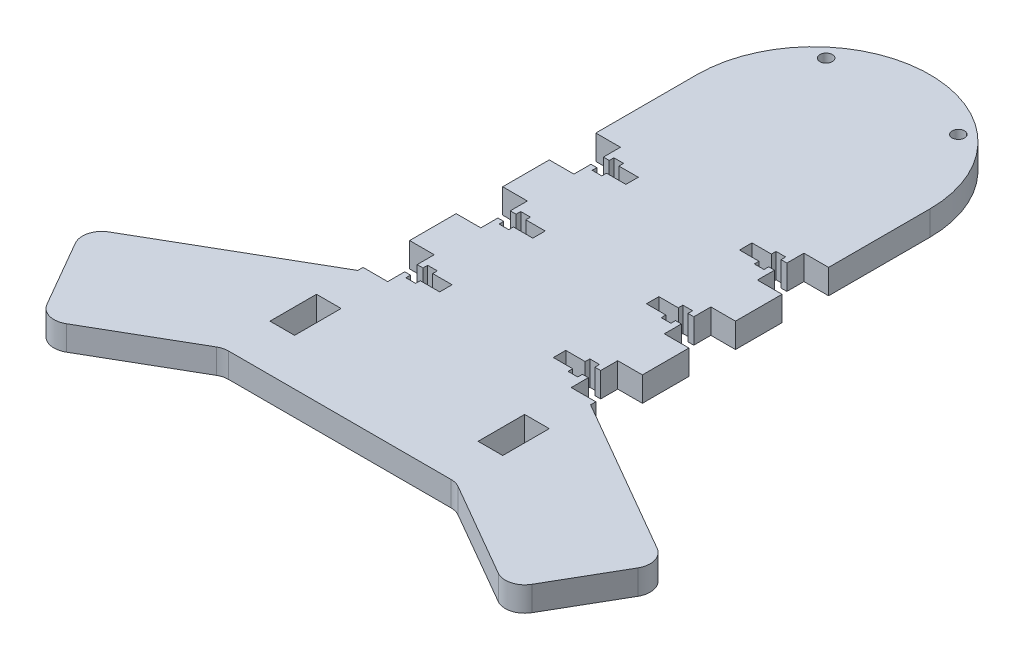
from build123d import *

# Parameters (mm, degrees)
BOSS_EXTRUDE1_DEPTH = 6.35
CUT_EXTRUDE1_REACH  = 8.35
SKETCH3_W           = 6.35
SKETCH3_H           = 12
CUT_EXTRUDE2_REACH  = 8.35
SKETCH5_R           = 1.6
CUT_EXTRUDE3_DEPTH  = 7.35
FILLET1_R           = 5


with BuildPart() as part:
    # Sketch1 → Boss-Extrude1 (new body)
    with BuildSketch(Plane(origin=(0, 0, 0), x_dir=(1, 0, 0), z_dir=(0, 1, 0))):
        with BuildLine():
            Line((-30, -122.105), (30, -122.105))
            Line((30, -122.105), (60, -139.425508076))
            Line((60, -139.425508076), (75, -113.444745962))
            Line((75, -113.444745962), (30, -87.463983849))
            Line((30, -87.463983849), (30, 0))
            ThreePointArc((30, 0), (0, 30), (-30, 0))
            Line((-30, 0), (-30, -87.463983849))
            Line((-30, -87.463983849), (-75, -113.444745962))
            Line((-75, -113.444745962), (-60, -139.425508076))
            Line((-60, -139.425508076), (-30, -122.105))
        make_face()
    extrude(amount=BOSS_EXTRUDE1_DEPTH)

    # Sketch3 → Cut-Extrude1 (cut, up to next)
    with BuildSketch(Plane(origin=(0, 6.35, 0), x_dir=(1, 0, 0), z_dir=(0, 1, 0)), mode=Mode.PRIVATE) as cut_extrude1_sk1:
        with Locations((-26.825, -104.105)):
            Rectangle(SKETCH3_W, SKETCH3_H)
    cut_extrude1_tool1 = extrude(cut_extrude1_sk1.sketch, amount=-CUT_EXTRUDE1_REACH, mode=Mode.PRIVATE) & part.part
    add(cut_extrude1_tool1.solids().sort_by_distance((-26.825, 6.35, 104.105))[0], mode=Mode.SUBTRACT)
    # Sketch3 → Cut-Extrude1 (cut, up to next)
    with BuildSketch(Plane(origin=(0, 6.35, 0), x_dir=(1, 0, 0), z_dir=(0, 1, 0)), mode=Mode.PRIVATE) as cut_extrude1_sk2:
        with Locations((-26.825, -80.105)):
            Rectangle(SKETCH3_W, SKETCH3_H)
    cut_extrude1_tool2 = extrude(cut_extrude1_sk2.sketch, amount=-CUT_EXTRUDE1_REACH, mode=Mode.PRIVATE) & part.part
    add(cut_extrude1_tool2.solids().sort_by_distance((-26.825, 6.35, 80.105))[0], mode=Mode.SUBTRACT)
    # Sketch3 → Cut-Extrude1 (cut, up to next)
    with BuildSketch(Plane(origin=(0, 6.35, 0), x_dir=(1, 0, 0), z_dir=(0, 1, 0)), mode=Mode.PRIVATE) as cut_extrude1_sk3:
        with Locations((-26.825, -56.105)):
            Rectangle(SKETCH3_W, SKETCH3_H)
    cut_extrude1_tool3 = extrude(cut_extrude1_sk3.sketch, amount=-CUT_EXTRUDE1_REACH, mode=Mode.PRIVATE) & part.part
    add(cut_extrude1_tool3.solids().sort_by_distance((-26.825, 6.35, 56.105))[0], mode=Mode.SUBTRACT)
    # Sketch3 → Cut-Extrude1 (cut, up to next)
    with BuildSketch(Plane(origin=(0, 6.35, 0), x_dir=(1, 0, 0), z_dir=(0, 1, 0)), mode=Mode.PRIVATE) as cut_extrude1_sk4:
        with Locations((-26.825, -32.105)):
            Rectangle(SKETCH3_W, SKETCH3_H)
    cut_extrude1_tool4 = extrude(cut_extrude1_sk4.sketch, amount=-CUT_EXTRUDE1_REACH, mode=Mode.PRIVATE) & part.part
    add(cut_extrude1_tool4.solids().sort_by_distance((-26.825, 6.35, 32.105))[0], mode=Mode.SUBTRACT)
    # Sketch3 → Cut-Extrude1 (cut, up to next)
    with BuildSketch(Plane(origin=(0, 6.35, 0), x_dir=(1, 0, 0), z_dir=(0, 1, 0)), mode=Mode.PRIVATE) as cut_extrude1_sk5:
        with Locations((26.825, -32.105)):
            Rectangle(SKETCH3_W, SKETCH3_H)
    cut_extrude1_tool5 = extrude(cut_extrude1_sk5.sketch, amount=-CUT_EXTRUDE1_REACH, mode=Mode.PRIVATE) & part.part
    add(cut_extrude1_tool5.solids().sort_by_distance((26.825, 6.35, 32.105))[0], mode=Mode.SUBTRACT)
    # Sketch3 → Cut-Extrude1 (cut, up to next)
    with BuildSketch(Plane(origin=(0, 6.35, 0), x_dir=(1, 0, 0), z_dir=(0, 1, 0)), mode=Mode.PRIVATE) as cut_extrude1_sk6:
        with Locations((26.825, -56.105)):
            Rectangle(SKETCH3_W, SKETCH3_H)
    cut_extrude1_tool6 = extrude(cut_extrude1_sk6.sketch, amount=-CUT_EXTRUDE1_REACH, mode=Mode.PRIVATE) & part.part
    add(cut_extrude1_tool6.solids().sort_by_distance((26.825, 6.35, 56.105))[0], mode=Mode.SUBTRACT)
    # Sketch3 → Cut-Extrude1 (cut, up to next)
    with BuildSketch(Plane(origin=(0, 6.35, 0), x_dir=(1, 0, 0), z_dir=(0, 1, 0)), mode=Mode.PRIVATE) as cut_extrude1_sk7:
        with Locations((26.825, -80.105)):
            Rectangle(SKETCH3_W, SKETCH3_H)
    cut_extrude1_tool7 = extrude(cut_extrude1_sk7.sketch, amount=-CUT_EXTRUDE1_REACH, mode=Mode.PRIVATE) & part.part
    add(cut_extrude1_tool7.solids().sort_by_distance((26.825, 6.35, 80.105))[0], mode=Mode.SUBTRACT)
    # Sketch3 → Cut-Extrude1 (cut, up to next)
    with BuildSketch(Plane(origin=(0, 6.35, 0), x_dir=(1, 0, 0), z_dir=(0, 1, 0)), mode=Mode.PRIVATE) as cut_extrude1_sk8:
        with Locations((26.825, -104.105)):
            Rectangle(SKETCH3_W, SKETCH3_H)
    cut_extrude1_tool8 = extrude(cut_extrude1_sk8.sketch, amount=-CUT_EXTRUDE1_REACH, mode=Mode.PRIVATE) & part.part
    add(cut_extrude1_tool8.solids().sort_by_distance((26.825, 6.35, 104.105))[0], mode=Mode.SUBTRACT)

    # Sketch4 → Cut-Extrude2 (cut, up to next)
    with BuildSketch(Plane(origin=(0, 6.35, 0), x_dir=(1, 0, 0), z_dir=(0, 1, 0)), mode=Mode.PRIVATE) as cut_extrude2_sk1:
        Polygon((23.65, -30.505), (22.15, -30.505), (22.15, -29.305), (19.65, -29.305), (19.65, -30.505), (14.65, -30.505), (14.65, -33.705), (19.65, -33.705), (19.65, -34.905), (22.15, -34.905), (22.15, -33.705), (23.65, -33.705), align=None)
    cut_extrude2_tool1 = extrude(cut_extrude2_sk1.sketch, amount=-CUT_EXTRUDE2_REACH, mode=Mode.PRIVATE) & part.part
    add(cut_extrude2_tool1.solids().sort_by_distance((19.451724, 6.35, 32.105))[0], mode=Mode.SUBTRACT)
    # Sketch4 → Cut-Extrude2 (cut, up to next)
    with BuildSketch(Plane(origin=(0, 6.35, 0), x_dir=(1, 0, 0), z_dir=(0, 1, 0)), mode=Mode.PRIVATE) as cut_extrude2_sk2:
        Polygon((22.15, -53.305), (19.65, -53.305), (19.65, -54.505), (14.65, -54.505), (14.65, -57.705), (19.65, -57.705), (19.65, -58.905), (22.15, -58.905), (22.15, -57.705), (23.65, -57.705), (23.65, -54.505), (22.15, -54.505), align=None)
    cut_extrude2_tool2 = extrude(cut_extrude2_sk2.sketch, amount=-CUT_EXTRUDE2_REACH, mode=Mode.PRIVATE) & part.part
    add(cut_extrude2_tool2.solids().sort_by_distance((19.451724, 6.35, 56.105))[0], mode=Mode.SUBTRACT)
    # Sketch4 → Cut-Extrude2 (cut, up to next)
    with BuildSketch(Plane(origin=(0, 6.35, 0), x_dir=(1, 0, 0), z_dir=(0, 1, 0)), mode=Mode.PRIVATE) as cut_extrude2_sk3:
        Polygon((22.15, -77.305), (19.65, -77.305), (19.65, -78.505), (14.65, -78.505), (14.65, -81.705), (19.65, -81.705), (19.65, -82.905), (22.15, -82.905), (22.15, -81.705), (23.65, -81.705), (23.65, -78.505), (22.15, -78.505), align=None)
    cut_extrude2_tool3 = extrude(cut_extrude2_sk3.sketch, amount=-CUT_EXTRUDE2_REACH, mode=Mode.PRIVATE) & part.part
    add(cut_extrude2_tool3.solids().sort_by_distance((19.451724, 6.35, 80.105))[0], mode=Mode.SUBTRACT)
    # Sketch4 → Cut-Extrude2 (cut, up to next)
    with BuildSketch(Plane(origin=(0, 6.35, 0), x_dir=(1, 0, 0), z_dir=(0, 1, 0)), mode=Mode.PRIVATE) as cut_extrude2_sk4:
        Polygon((-22.15, -78.505), (-22.15, -77.305), (-19.65, -77.305), (-19.65, -78.505), (-14.65, -78.505), (-14.65, -81.705), (-19.65, -81.705), (-19.65, -82.905), (-22.15, -82.905), (-22.15, -81.705), (-23.65, -81.705), (-23.65, -78.505), align=None)
    cut_extrude2_tool4 = extrude(cut_extrude2_sk4.sketch, amount=-CUT_EXTRUDE2_REACH, mode=Mode.PRIVATE) & part.part
    add(cut_extrude2_tool4.solids().sort_by_distance((-19.451724, 6.35, 80.105))[0], mode=Mode.SUBTRACT)
    # Sketch4 → Cut-Extrude2 (cut, up to next)
    with BuildSketch(Plane(origin=(0, 6.35, 0), x_dir=(1, 0, 0), z_dir=(0, 1, 0)), mode=Mode.PRIVATE) as cut_extrude2_sk5:
        Polygon((-22.15, -54.505), (-22.15, -53.305), (-19.65, -53.305), (-19.65, -54.505), (-14.65, -54.505), (-14.65, -57.705), (-19.65, -57.705), (-19.65, -58.905), (-22.15, -58.905), (-22.15, -57.705), (-23.65, -57.705), (-23.65, -54.505), align=None)
    cut_extrude2_tool5 = extrude(cut_extrude2_sk5.sketch, amount=-CUT_EXTRUDE2_REACH, mode=Mode.PRIVATE) & part.part
    add(cut_extrude2_tool5.solids().sort_by_distance((-19.451724, 6.35, 56.105))[0], mode=Mode.SUBTRACT)
    # Sketch4 → Cut-Extrude2 (cut, up to next)
    with BuildSketch(Plane(origin=(0, 6.35, 0), x_dir=(1, 0, 0), z_dir=(0, 1, 0)), mode=Mode.PRIVATE) as cut_extrude2_sk6:
        Polygon((-19.65, -33.705), (-14.65, -33.705), (-14.65, -30.505), (-19.65, -30.505), (-19.65, -29.305), (-22.15, -29.305), (-22.15, -30.505), (-23.65, -30.505), (-23.65, -33.705), (-22.15, -33.705), (-22.15, -34.905), (-19.65, -34.905), align=None)
    cut_extrude2_tool6 = extrude(cut_extrude2_sk6.sketch, amount=-CUT_EXTRUDE2_REACH, mode=Mode.PRIVATE) & part.part
    add(cut_extrude2_tool6.solids().sort_by_distance((-19.451724, 6.35, 32.105))[0], mode=Mode.SUBTRACT)

    # Sketch5 → Cut-Extrude3 (cut, through all)
    with BuildSketch(Plane(origin=(0, 6.35, 0), x_dir=(1, 0, 0), z_dir=(0, 1, 0))):
        with Locations((-17.033871657, 20.300177743)):
            Circle(SKETCH5_R)
        with Locations((17.033871657, 20.300177743)):
            Circle(SKETCH5_R)
    extrude(amount=-CUT_EXTRUDE3_DEPTH, mode=Mode.SUBTRACT)

    # Fillet1
    fillet1_edges = [part.edges().sort_by_distance(p)[0] for p in [
        (75, 3.175, 113.444745962),
        (60, 3.175, 139.425508076),
        (30, 3.175, 122.105),
        (-30, 3.175, 122.105),
        (-60, 3.175, 139.425508076),
        (-75, 3.175, 113.444745962),
    ]]
    fillet(fillet1_edges, radius=FILLET1_R)


solid = part.part
